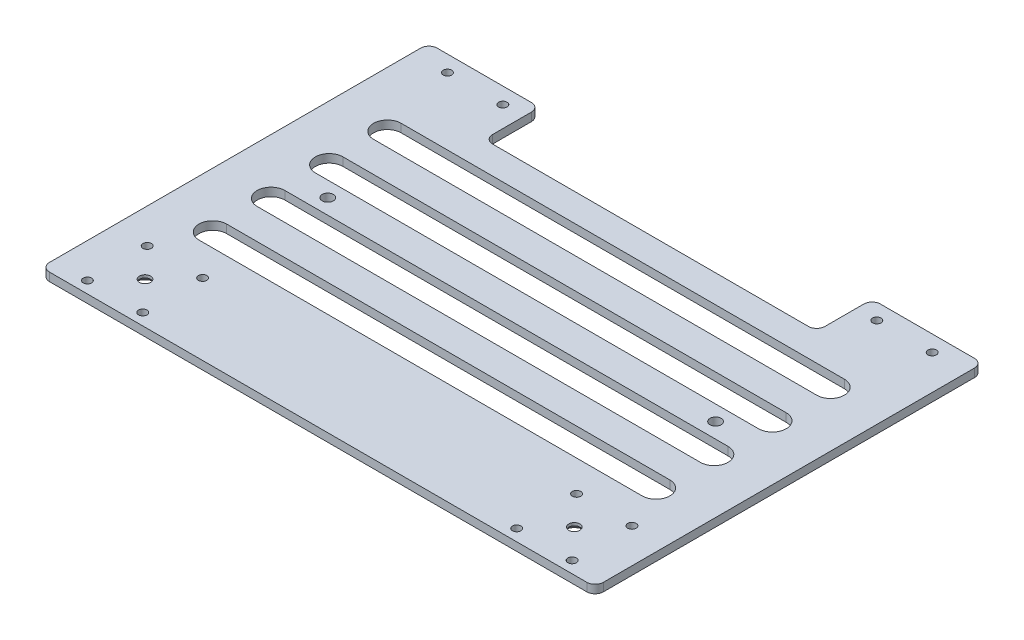
from build123d import *

# Parameters (mm, degrees)
SKETCH_1_W          = 200
SKETCH_1_H          = 120
EXTRUDE_1_DEPTH     = 3
SKETCH_2_R          = 1.525
CUT_EXTRUDE_1_DEPTH = 3
SKETCH_3_W          = 120
SKETCH_3_H          = 40
CUT_EXTRUDE_2_DEPTH = 3
CUT_EXTRUDE_3_DEPTH = 10
SKETCH_5_W          = 200
SKETCH_5_H          = 20
EXTRUDE_2_DEPTH     = 3
SKETCH_7_R          = 1.525
CUT_EXTRUDE_4_DEPTH = 4
SKETCH_14_R         = 2.025
CUT_EXTRUDE_5_DEPTH = 4
SKETCH_15_R         = 2.025
CUT_EXTRUDE_6_DEPTH = 4
FILLET_1_R          = 3


with BuildPart() as part:
    # 草图1 → 凸台-拉伸1 (new body)
    with BuildSketch(Plane(origin=(0, 0, 0), x_dir=(1, 0, 0), z_dir=(0, 1, 0))):
        Rectangle(SKETCH_1_W, SKETCH_1_H)
    extrude(amount=EXTRUDE_1_DEPTH)

    # 草图2 → 切除-拉伸1 (cut)
    with BuildSketch(Plane(origin=(0, 3, 0), x_dir=(1, 0, 0), z_dir=(0, 1, 0))):
        with Locations((67.5, 54.2)):
            Circle(SKETCH_2_R)
        with Locations((87.5, 54.2)):
            Circle(SKETCH_2_R)
        with Locations((67.5, -54.2)):
            Circle(SKETCH_2_R)
        with Locations((87.5, -54.2)):
            Circle(SKETCH_2_R)
        with Locations((-87.5, -54.2)):
            Circle(SKETCH_2_R)
        with Locations((-67.5, -54.2)):
            Circle(SKETCH_2_R)
        with Locations((-87.5, 54.2)):
            Circle(SKETCH_2_R)
        with Locations((-67.5, 54.2)):
            Circle(SKETCH_2_R)
    extrude(amount=-CUT_EXTRUDE_1_DEPTH, mode=Mode.SUBTRACT)

    # 草图3 → 切除-拉伸2 (cut)
    with BuildSketch(Plane(origin=(0, 3, 0), x_dir=(1, 0, 0), z_dir=(0, 1, 0))):
        with Locations((0, 60)):
            Rectangle(SKETCH_3_W, SKETCH_3_H)
    extrude(amount=-CUT_EXTRUDE_2_DEPTH, mode=Mode.SUBTRACT)

    # 草图4 → 切除-拉伸3 (cut)
    with BuildSketch(Plane(origin=(0, 3, 0), x_dir=(1, 0, 0), z_dir=(0, 1, 0))):
        with BuildLine():
            Line((-80, 30), (80, 30))
            ThreePointArc((80, 30), (85, 25), (80, 20))
            Line((80, 20), (-80, 20))
            ThreePointArc((-80, 20), (-85, 25), (-80, 30))
        make_face()
        with BuildLine():
            Line((-80, 9), (80, 9))
            ThreePointArc((80, 9), (85, 4), (80, -1))
            Line((80, -1), (-80, -1))
            ThreePointArc((-80, -1), (-85, 4), (-80, 9))
        make_face()
        with BuildLine():
            Line((-80, -12), (80, -12))
            ThreePointArc((80, -12), (85, -17), (80, -22))
            Line((80, -22), (-80, -22))
            ThreePointArc((-80, -22), (-85, -17), (-80, -12))
        make_face()
        with BuildLine():
            Line((-80, -33), (80, -33))
            ThreePointArc((80, -33), (85, -38), (80, -43))
            Line((80, -43), (-80, -43))
            ThreePointArc((-80, -43), (-85, -38), (-80, -33))
        make_face()
    extrude(amount=-CUT_EXTRUDE_3_DEPTH, mode=Mode.SUBTRACT)

    # 草图5 → 凸台-拉伸2 (add)
    with BuildSketch(Plane(origin=(0, 3, 0), x_dir=(1, 0, 0), z_dir=(0, 1, 0))):
        with Locations((0, -70)):
            Rectangle(SKETCH_5_W, SKETCH_5_H)
    extrude(amount=-EXTRUDE_2_DEPTH)

    # 草图7 → 切除-拉伸4 (cut, through all)
    with BuildSketch(Plane(origin=(0, 3, 0), x_dir=(1, 0, 0), z_dir=(0, 1, 0))):
        with Locations((-87.5, -75.8)):
            Circle(SKETCH_7_R)
        with Locations((-67.5, -75.8)):
            Circle(SKETCH_7_R)
    cut_extrude_4 = extrude(amount=-CUT_EXTRUDE_4_DEPTH, mode=Mode.SUBTRACT)

    # 镜向1: 切除-拉伸4 across plane
    add(cut_extrude_4.mirror(Plane(origin=(0, 0, 0), x_dir=(0, 0, 1), z_dir=(1, 0, 0))), mode=Mode.SUBTRACT)

    # 草图12 → 孔2 (revolve, cut)
    with BuildSketch(Plane(origin=(-77.5, 0, 65), x_dir=(0, 0, -1), z_dir=(1, 0, 0))):
        Polygon((0, 0), (0, 3), (2, 3), (2, 2), (4, 0), align=None)
    hole_wizard_2 = revolve(axis=Axis((-77.5, -6.445314094, 65), (0, 1, 0)), mode=Mode.SUBTRACT)

    # 镜向3: 孔2 across plane
    add(hole_wizard_2.mirror(Plane(origin=(0, 0, 0), x_dir=(0, 0, 1), z_dir=(1, 0, 0))), mode=Mode.SUBTRACT)

    # 草图14 → 切除-拉伸5 (cut, through all)
    with BuildSketch(Plane.XZ):
        with Locations((-70, 6.5)):
            Circle(SKETCH_14_R)
    cut_extrude_5 = extrude(amount=-CUT_EXTRUDE_5_DEPTH, mode=Mode.SUBTRACT)

    # 镜向4: 切除-拉伸5 across plane
    add(cut_extrude_5.mirror(Plane(origin=(0, 0, 0), x_dir=(0, 0, 1), z_dir=(1, 0, 0))), mode=Mode.SUBTRACT)

    # 草图15 → 切除-拉伸6 (cut, through all)
    with BuildSketch(Plane.XZ):
        with Locations((0, 27.5)):
            Circle(SKETCH_15_R)
    extrude(amount=-CUT_EXTRUDE_6_DEPTH, mode=Mode.SUBTRACT)

    # 圆角1
    fillet_1_edges = [part.edges().sort_by_distance(p)[0] for p in [
        (-100, 1.5, 80),
        (100, 1.5, 80),
        (60, 1.5, -60),
        (-60, 1.5, -60),
        (-60, 1.5, -40),
        (60, 1.5, -40),
        (-100, 1.5, -60),
        (100, 1.5, -60),
    ]]
    fillet(fillet_1_edges, radius=FILLET_1_R)


solid = part.part
